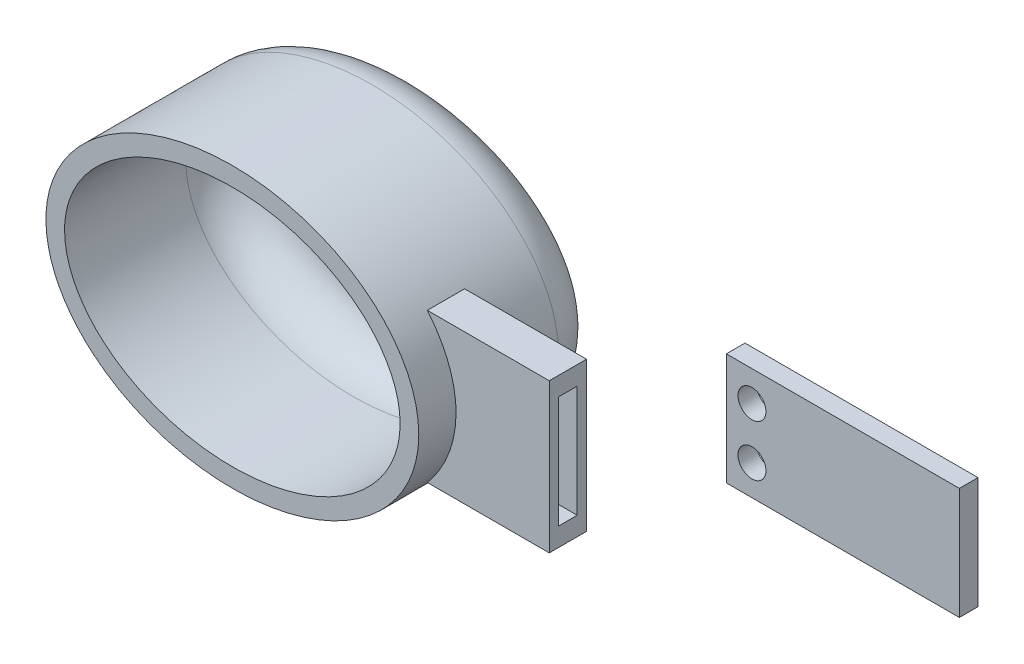
from build123d import *

# Parameters (mm, degrees)
SKETCH1_RX          = 20
SKETCH1_RY          = 15
BOSS_EXTRUDE1_DEPTH = 20
SHELL1_T            = -2
FILLET3_R           = 5
FILLET4_R           = 5
BOSS_EXTRUDE3_DEPTH = 8
CUT_EXTRUDE2_DEPTH  = 4
SKETCH12_W          = 2
SKETCH12_H          = 12
CUT_EXTRUDE3_DEPTH  = 8
SKETCH13_W          = 25
SKETCH13_H          = 12
BOSS_EXTRUDE4_DEPTH = 2
SKETCH15_R          = 1.5
CUT_EXTRUDE4_DEPTH  = 10


with BuildPart() as part:
    # Sketch1 → Boss-Extrude1 (new body)
    with BuildSketch(Plane.XY):
        with Locations((0, 0)):
            Ellipse(SKETCH1_RX, SKETCH1_RY)
    extrude(amount=BOSS_EXTRUDE1_DEPTH)

    # Shell1
    shell1_openings = [part.faces().sort_by_distance(p)[0] for p in [
        (0, 0, 20),
    ]]
    offset(amount=SHELL1_T, openings=shell1_openings, kind=Kind.INTERSECTION)

    # Fillet3
    fillet3_edges = [part.edges().sort_by_distance(p)[0] for p in [
        (-18.000000048, 7.4e-08, 2),
    ]]
    fillet(fillet3_edges, radius=FILLET3_R)

    # Fillet4
    fillet4_edges = [part.edges().sort_by_distance(p)[0] for p in [
        (-19.999998775, -0.005250576, 0),
    ]]
    fillet(fillet4_edges, radius=FILLET4_R)

    # Sketch3 → Boss-Extrude3 (add)
    with BuildSketch(Plane.XY.offset(20)):
        with BuildLine():
            Line((30, 8), (30, -8))
            Line((30, -8), (16.918103387, -8))
            add(Edge.make_bspline(
                [(16.918103387, -8), (23.643312187, 0), (16.918103387, 8)],
                knots=[5.720649063, 5.720649063, 5.720649063, 6.845721552, 6.845721552, 6.845721552], degree=2, weights=[1, 0.845905169, 1]))
            Line((16.918103387, 8), (30, 8))
        make_face()
    extrude(amount=-BOSS_EXTRUDE3_DEPTH)

    # Sketch3_3 → Cut-Extrude2 (cut)
    with BuildSketch(Plane.XY.offset(20)):
        with BuildLine():
            Line((30, 8), (30, -8))
            Line((30, -8), (16.918103387, -8))
            add(Edge.make_bspline(
                [(16.918103387, -8), (23.643312187, 0), (16.918103387, 8)],
                knots=[5.720649063, 5.720649063, 5.720649063, 6.845721552, 6.845721552, 6.845721552], degree=2, weights=[1, 0.845905169, 1]))
            Line((16.918103387, 8), (30, 8))
        make_face()
    extrude(amount=-CUT_EXTRUDE2_DEPTH, mode=Mode.SUBTRACT)

    # Sketch12 → Cut-Extrude3 (cut)
    with BuildSketch(Plane(origin=(30, 0, 0), x_dir=(0, 0, -1), z_dir=(1, 0, 0))):
        with Locations((-14, 0)):
            Rectangle(SKETCH12_W, SKETCH12_H)
    extrude(amount=-CUT_EXTRUDE3_DEPTH, mode=Mode.SUBTRACT)


with BuildPart() as body_2:
    # Sketch13 → Boss-Extrude4 (new body)
    with BuildSketch(Plane.XY):
        with Locations((47.5, 0)):
            Rectangle(SKETCH13_W, SKETCH13_H)
    extrude(amount=BOSS_EXTRUDE4_DEPTH)

    # Sketch15 → Cut-Extrude4 (cut)
    with BuildSketch(Plane.XY.offset(2)):
        with Locations((37.75, -2.75)):
            Circle(SKETCH15_R)
        with Locations((37.75, 2.75)):
            Circle(SKETCH15_R)
    extrude(amount=-CUT_EXTRUDE4_DEPTH, mode=Mode.SUBTRACT)


solid = Compound([part.part, body_2.part])
